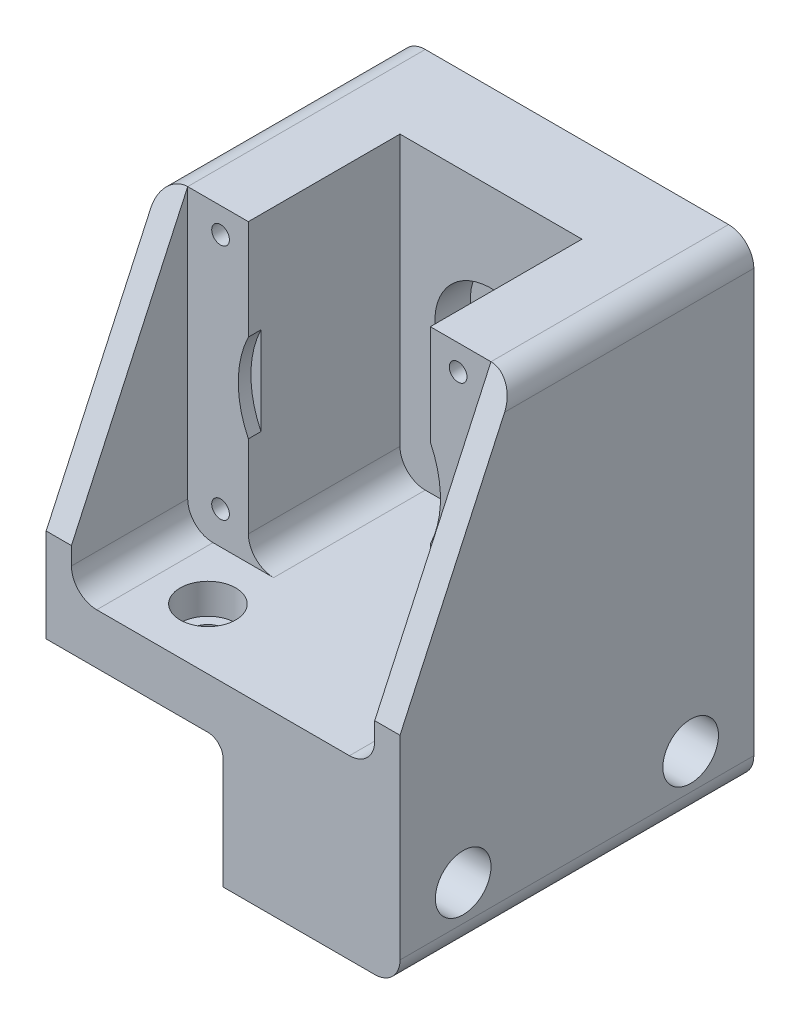
from build123d import *

# Parameters (mm, degrees)
SKETCH1_R                                       = 1.75
SKETCH1_R_2                                     = 6
BOSS_EXTRUDE1_DEPTH                             = 70
SKETCH2_W                                       = 60
SKETCH2_H                                       = 58.5
CUT_EXTRUDE2_DEPTH                              = 23
CUT_EXTRUDE3_DEPTH                              = 53
CUT_EXTRUDE5_START                              = -23
CUT_EXTRUDE5_DEPTH                              = 2.5
SKETCH5_R                                       = 11.1
CUT_EXTRUDE4_DEPTH                              = 7
CHAMFER1_SIZE                                   = 50
CHAMFER1_SIZE2                                  = 23
FILLET1_R                                       = 5
FILLET2_R                                       = 5
CBORE_FOR_M6_SOCKET_HEAD_CAP_SCREW1_D           = 7
CBORE_FOR_M6_SOCKET_HEAD_CAP_SCREW1_CBORE_D     = 11
CBORE_FOR_M6_SOCKET_HEAD_CAP_SCREW1_CBORE_DEPTH = 6
CBORE_FOR_M6_SOCKET_HEAD_CAP_SCREW2_D           = 7
CBORE_FOR_M6_SOCKET_HEAD_CAP_SCREW2_CBORE_D     = 11
CBORE_FOR_M6_SOCKET_HEAD_CAP_SCREW2_CBORE_DEPTH = 15
CHAMFER2_SIZE                                   = 1


with BuildPart() as part:
    # Sketch1 → Boss-Extrude1 (new body)
    with BuildSketch(Plane.XY):
        with BuildLine():
            Line((35, 28.5), (-35, 28.5))
            Line((-35, 28.5), (-35, -25))
            Line((-35, -25), (-35, -40))
            Line((-35, -40), (-3, -40))
            ThreePointArc((-3, -40), (-0.878679656, -40.878679656), (0, -43))
            Line((0, -43), (0, -65))
            Line((0, -65), (35, -65))
            Line((35, -65), (35, -25))
            Line((35, -25), (35, 28.5))
        make_face()
        with Locations((-23.5, -23.5)):
            Circle(SKETCH1_R, mode=Mode.SUBTRACT)
        with Locations((23.5, -23.5)):
            Circle(SKETCH1_R, mode=Mode.SUBTRACT)
        Circle(SKETCH1_R_2, mode=Mode.SUBTRACT)
        with Locations((-23.5, 23.5)):
            Circle(SKETCH1_R, mode=Mode.SUBTRACT)
        with Locations((23.5, 23.5)):
            Circle(SKETCH1_R, mode=Mode.SUBTRACT)
    extrude(amount=-BOSS_EXTRUDE1_DEPTH)

    # Sketch2 → Cut-Extrude2 (cut)
    with BuildSketch(Plane.XY):
        with Locations((0, -0.75)):
            Rectangle(SKETCH2_W, SKETCH2_H)
    extrude(amount=-CUT_EXTRUDE2_DEPTH, mode=Mode.SUBTRACT)

    # Sketch6 → Cut-Extrude3 (cut)
    with BuildSketch(Plane.XY):
        Polygon((-18, -8.717797887), (-18, -30), (18, -30), (18, -8.717797887), (18, 8.717797887), (18, 28.5), (-18, 28.5), (-18, 8.717797887), align=None)
    extrude(amount=-CUT_EXTRUDE3_DEPTH, mode=Mode.SUBTRACT)

    # Sketch6_4 → Cut-Extrude5 (cut)
    with BuildSketch(Plane.XY.offset(CUT_EXTRUDE5_START)):
        with BuildLine():
            Line((-18, 8.717797887), (-18, -8.717797887))
            ThreePointArc((-18, -8.717797887), (-20, 0), (-18, 8.717797887))
        make_face()
        with BuildLine():
            Line((18, 8.717797887), (18, -8.717797887))
            ThreePointArc((18, -8.717797887), (20, 0), (18, 8.717797887))
        make_face()
    extrude(amount=-CUT_EXTRUDE5_DEPTH, mode=Mode.SUBTRACT)

    # Sketch5 → Cut-Extrude4 (cut)
    with BuildSketch(Plane.XY.offset(-53)):
        Circle(SKETCH5_R)
    extrude(amount=-CUT_EXTRUDE4_DEPTH, mode=Mode.SUBTRACT)

    # Chamfer1
    chamfer1_edges = [part.edges().sort_by_distance(p)[0] for p in [
        (32.5, 28.5, 0),
        (-32.5, 28.5, 0),
    ]]
    chamfer1_side = [part.faces().sort_by_distance(p)[0] for p in [
        (7.08218847, -32.820097977, 0),
    ]]
    chamfer(chamfer1_edges, length=CHAMFER1_SIZE, length2=CHAMFER1_SIZE2, reference=chamfer1_side[0])

    # Fillet1
    fillet1_edges = [part.edges().sort_by_distance(p)[0] for p in [
        (35, -65, -35),
        (35, 28.5, -46.5),
        (-35, 28.5, -46.5),
    ]]
    fillet(fillet1_edges, radius=FILLET1_R)

    # Fillet2
    fillet2_edges = [part.edges().sort_by_distance(p)[0] for p in [
        (30, -30, -11.5),
        (-30, -30, -11.5),
        (18, -30, -38),
        (-18, -30, -38),
    ]]
    fillet(fillet2_edges, radius=FILLET2_R)

    # CBORE for M6 Socket Head Cap Screw1 (through all)
    with Locations(Plane(origin=(-15, -30, -12), x_dir=(1, 0, 0), z_dir=(0, 1, 0))):
        with Locations((0, 0)):
            CounterBoreHole(CBORE_FOR_M6_SOCKET_HEAD_CAP_SCREW1_D / 2, CBORE_FOR_M6_SOCKET_HEAD_CAP_SCREW1_CBORE_D / 2, CBORE_FOR_M6_SOCKET_HEAD_CAP_SCREW1_CBORE_DEPTH)

    # CBORE for M6 Socket Head Cap Screw2 (through all)
    with Locations(Plane(origin=(35, 0, 0), x_dir=(0, 0, -1), z_dir=(1, 0, 0))):
        with Locations((12.5, -53), (57.5, -53)):
            CounterBoreHole(CBORE_FOR_M6_SOCKET_HEAD_CAP_SCREW2_D / 2, CBORE_FOR_M6_SOCKET_HEAD_CAP_SCREW2_CBORE_D / 2, CBORE_FOR_M6_SOCKET_HEAD_CAP_SCREW2_CBORE_DEPTH)

    # Chamfer2
    chamfer2_edges = [part.edges().sort_by_distance(p)[0] for p in [
        (-6, 0, -60),
    ]]
    chamfer(chamfer2_edges, length=CHAMFER2_SIZE)


solid = part.part
